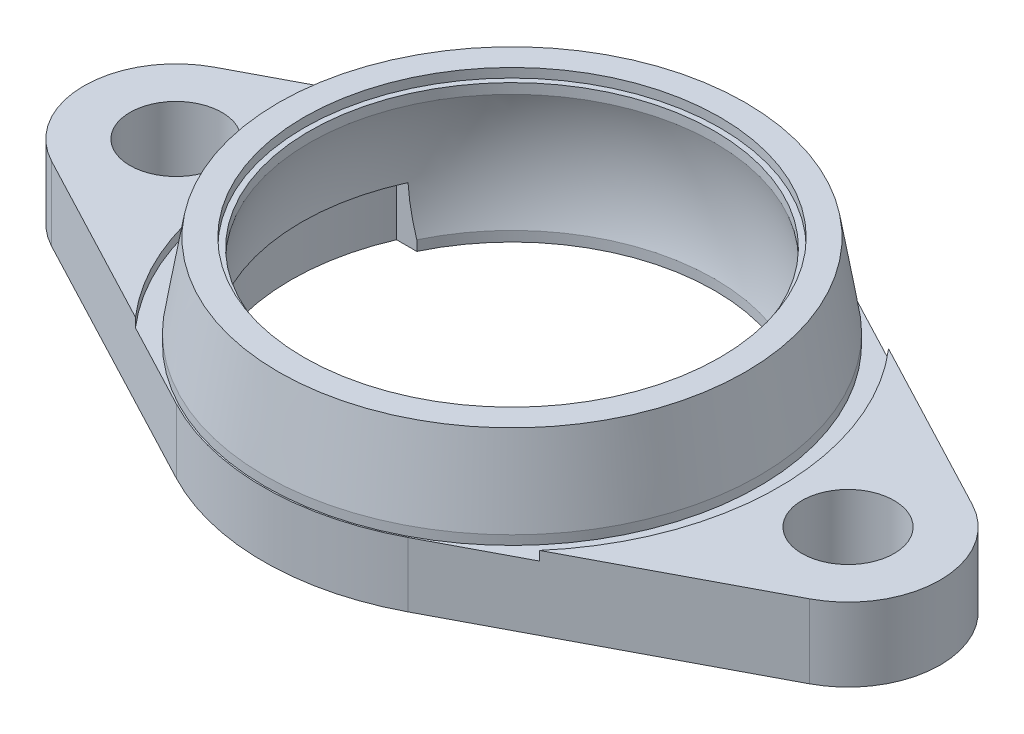
from build123d import *

# Parameters (mm, degrees)
SKETCH1_R              = 11
FLANGE_DEPTH           = 4
TOP_START              = -0.5
SKETCH3_R              = 13.425
TOP_RECESS_DEPTH       = 0.5
BOTTOM_RECESS_1_DEPTH  = 0.5
BOTTOM_RECESS_2_DEPTH  = 3
MOUNTING_HOLE_M5X0_8_D = 5


with BuildPart() as part:
    # Sketch1 → Flange (new body)
    with BuildSketch(Plane(origin=(0, 0, 0), x_dir=(1, 0, 0), z_dir=(0, 1, 0))):
        with BuildLine():
            Line((20.578767123, 4.424572712), (6.287671233, 11.946346323))
            ThreePointArc((6.287671233, 11.946346323), (0, 13.5), (-6.287671233, 11.946346323))
            Line((-6.287671233, 11.946346323), (-20.578767123, 4.424572712))
            ThreePointArc((-20.578767123, 4.424572712), (-23.25, 0), (-20.578767123, -4.424572712))
            Line((-20.578767123, -4.424572712), (-6.287671233, -11.946346323))
            ThreePointArc((-6.287671233, -11.946346323), (0, -13.5), (6.287671233, -11.946346323))
            Line((6.287671233, -11.946346323), (20.578767123, -4.424572712))
            ThreePointArc((20.578767123, -4.424572712), (23.25, 0), (20.578767123, 4.424572712))
        make_face()
        Circle(SKETCH1_R, mode=Mode.SUBTRACT)
    extrude(amount=FLANGE_DEPTH)

    # Sketch2 → Bearing Seat (revolve)
    with BuildSketch(Plane.XY):
        Polygon((-13.425, 4), (-12.675, 8.5), (-11.3, 8.5), (-11.3, 8), (-11, 8), (-11, 4), align=None)
    revolve(axis=Axis((0, 0, 0), (0, 1, 0)))

    # Sketch3 → Top Recess (cut)
    with BuildSketch(Plane(origin=(0, 4, 0), x_dir=(1, 0, 0), z_dir=(0, 1, 0)).offset(TOP_START)):
        with BuildLine():
            Line((10.970198855, 9.481810855), (6.287671233, 11.946346323))
            ThreePointArc((6.287671233, 11.946346323), (0, 13.5), (-6.287671233, 11.946346323))
            Line((-6.287671233, 11.946346323), (-10.970198855, 9.481810855))
            ThreePointArc((-10.970198855, 9.481810855), (-14.5, 0), (-10.970198855, -9.481810855))
            Line((-10.970198855, -9.481810855), (-6.287671233, -11.946346323))
            ThreePointArc((-6.287671233, -11.946346323), (0, -13.5), (6.287671233, -11.946346323))
            Line((6.287671233, -11.946346323), (10.970198855, -9.481810855))
            ThreePointArc((10.970198855, -9.481810855), (14.5, 0), (10.970198855, 9.481810855))
        make_face()
        Circle(SKETCH3_R, mode=Mode.SUBTRACT)
    extrude(amount=TOP_RECESS_DEPTH, mode=Mode.SUBTRACT)

    # Sketch5 → Bottom Recess 1 (cut)
    with BuildSketch(Plane.XZ):
        with BuildLine():
            Line((17.009424329, 4.325618107), (5.47260274, 10.397745874))
            ThreePointArc((5.47260274, 10.397745874), (0, 11.75), (-5.47260274, 10.397745874))
            Line((-5.47260274, 10.397745874), (-17.009424329, 4.325618107))
            ThreePointArc((-17.009424329, 4.325618107), (-13.75, 0), (-17.009424329, -4.325618107))
            Line((-17.009424329, -4.325618107), (-5.47260274, -10.397745874))
            ThreePointArc((-5.47260274, -10.397745874), (0, -11.75), (5.47260274, -10.397745874))
            Line((5.47260274, -10.397745874), (17.009424329, -4.325618107))
            ThreePointArc((17.009424329, -4.325618107), (13.75, 0), (17.009424329, 4.325618107))
        make_face()
    extrude(amount=-BOTTOM_RECESS_1_DEPTH, mode=Mode.SUBTRACT)

    # Sketch6 → Bottom Recess 2 (cut)
    with BuildSketch(Plane.XZ.offset(-0.5)):
        with BuildLine():
            Line((-11.01986842, 4.75), (11.01986842, 4.75))
            ThreePointArc((11.01986842, 4.75), (12, 0), (11.01986842, -4.75))
            Line((11.01986842, -4.75), (-11.01986842, -4.75))
            ThreePointArc((-11.01986842, -4.75), (-12, 0), (-11.01986842, 4.75))
        make_face()
    extrude(amount=-BOTTOM_RECESS_2_DEPTH, mode=Mode.SUBTRACT)

    # Mounting Hole _M5x0.8 (through all)
    with Locations(Plane(origin=(0, 4, 0), x_dir=(1, 0, 0), z_dir=(0, 1, 0))):
        with Locations((18.25, 0), (-18.25, 0)):
            Hole(MOUNTING_HOLE_M5X0_8_D / 2)

    # Sketch11 → Cut-Revolve1 (revolve, cut)
    with BuildSketch(Plane.XY):
        with BuildLine():
            Line((0, 15.70600279), (0, -7.20600279))
            ThreePointArc((0, -7.20600279), (11.45600279, 4.25), (0, 15.70600279))
        make_face()
    revolve(axis=Axis((0, 8.5, 0), (0, -1, 0)), mode=Mode.SUBTRACT)


solid = part.part
